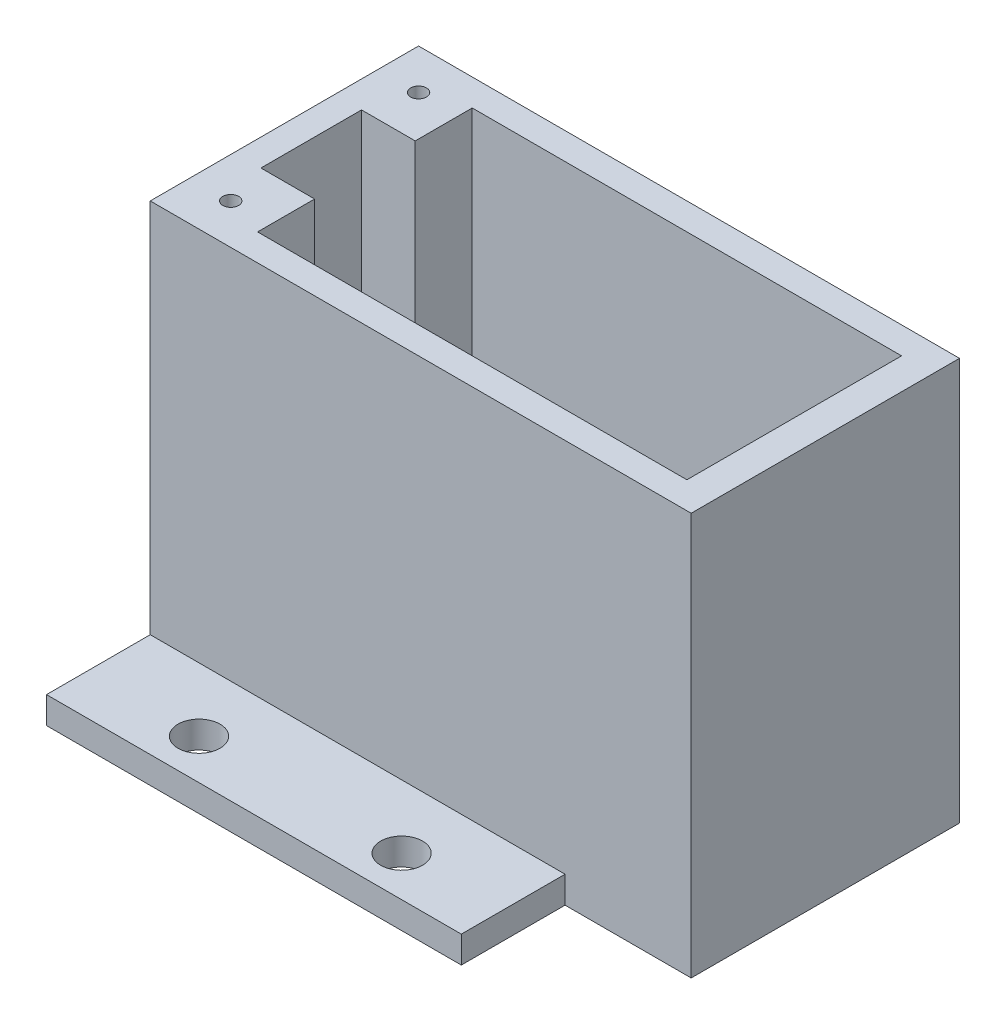
from build123d import *

# Parameters (mm, degrees)
SKETCH1_W                    = 91.186
SKETCH1_H                    = 90
SKETCH1_R                    = 3.96875
MOUNTING_PLATE_EXTRUDE_DEPTH = 5.08
SKETCH3_W                    = 102.41
SKETCH3_H                    = 50.8
MAIN_EXTRUDE_DEPTH           = 71.12
SKETCH4_W                    = 23.876
SKETCH4_H                    = 50.8
BOSS_EXTRUDE3_DEPTH          = 5.08
SKETCH5_R                    = 1.5
CUT_EXTRUDE1_DEPTH           = 25.4
SKETCH7_W                    = 12.652
SKETCH7_H                    = 90
CUT_EXTRUDE3_DEPTH           = 5.08
CUT_EXTRUDE4_DEPTH           = 5.08


with BuildPart() as part:
    # Sketch1 → Mounting plate extrude (new body)
    with BuildSketch(Plane(origin=(0, 0, 0), x_dir=(1, 0, 0), z_dir=(0, 1, 0))):
        Rectangle(SKETCH1_W, SKETCH1_H)
        with Locations((26.67, -37.38)):
            Circle(SKETCH1_R, mode=Mode.SUBTRACT)
        with Locations((-11.684, -37.38)):
            Circle(SKETCH1_R, mode=Mode.SUBTRACT)
        with Locations((-11.684, 37.38)):
            Circle(SKETCH1_R, mode=Mode.SUBTRACT)
        with Locations((26.67, 37.38)):
            Circle(SKETCH1_R, mode=Mode.SUBTRACT)
    extrude(amount=MOUNTING_PLATE_EXTRUDE_DEPTH)

    # Sketch3 → Main extrude (add)
    with BuildSketch(Plane(origin=(0, 5.08, 0), x_dir=(1, 0, 0), z_dir=(0, 1, 0))):
        with Locations((18.264, 0.042)):
            Rectangle(SKETCH3_W, SKETCH3_H)
        Polygon((-17.701, 9.567), (-17.701, 20.362), (63.579, 20.362), (63.579, 9.567), (63.579, -9.483), (63.579, -20.278), (-17.701, -20.278), (-17.701, -9.483), (-27.861, -9.483), (-27.861, 9.567), align=None, mode=Mode.SUBTRACT)
    extrude(amount=MAIN_EXTRUDE_DEPTH)

    # Sketch4 → Boss-Extrude3 (add)
    with BuildSketch(Plane.XZ.offset(-5.08)):
        with Locations((57.531, -0.042)):
            Rectangle(SKETCH4_W, SKETCH4_H)
    extrude(amount=BOSS_EXTRUDE3_DEPTH)

    # Sketch5 → Cut-Extrude1 (cut)
    with BuildSketch(Plane(origin=(0, 76.2, 0), x_dir=(1, 0, 0), z_dir=(0, 1, 0))):
        with Locations((-25.321, 17.822)):
            Circle(SKETCH5_R)
        with Locations((-25.321, -17.738)):
            Circle(SKETCH5_R)
    extrude(amount=-CUT_EXTRUDE1_DEPTH, mode=Mode.SUBTRACT)

    # Sketch7 → Cut-Extrude3 (cut)
    with BuildSketch(Plane(origin=(0, 5.08, 0), x_dir=(1, 0, 0), z_dir=(0, 1, 0))):
        with Locations((-39.267, 0)):
            Rectangle(SKETCH7_W, SKETCH7_H)
    extrude(amount=-CUT_EXTRUDE3_DEPTH, mode=Mode.SUBTRACT)

    # Sketch8 → Cut-Extrude4 (cut)
    with BuildSketch(Plane(origin=(0, 5.08, 0), x_dir=(1, 0, 0), z_dir=(0, 1, 0))):
        Polygon((-17.701, 20.362), (-17.701, 9.567), (-27.861, 9.567), (-27.861, -9.483), (-17.701, -9.483), (-17.701, -20.278), (63.579, -20.278), (63.579, 20.362), align=None)
    extrude(amount=-CUT_EXTRUDE4_DEPTH, mode=Mode.SUBTRACT)


solid = part.part
